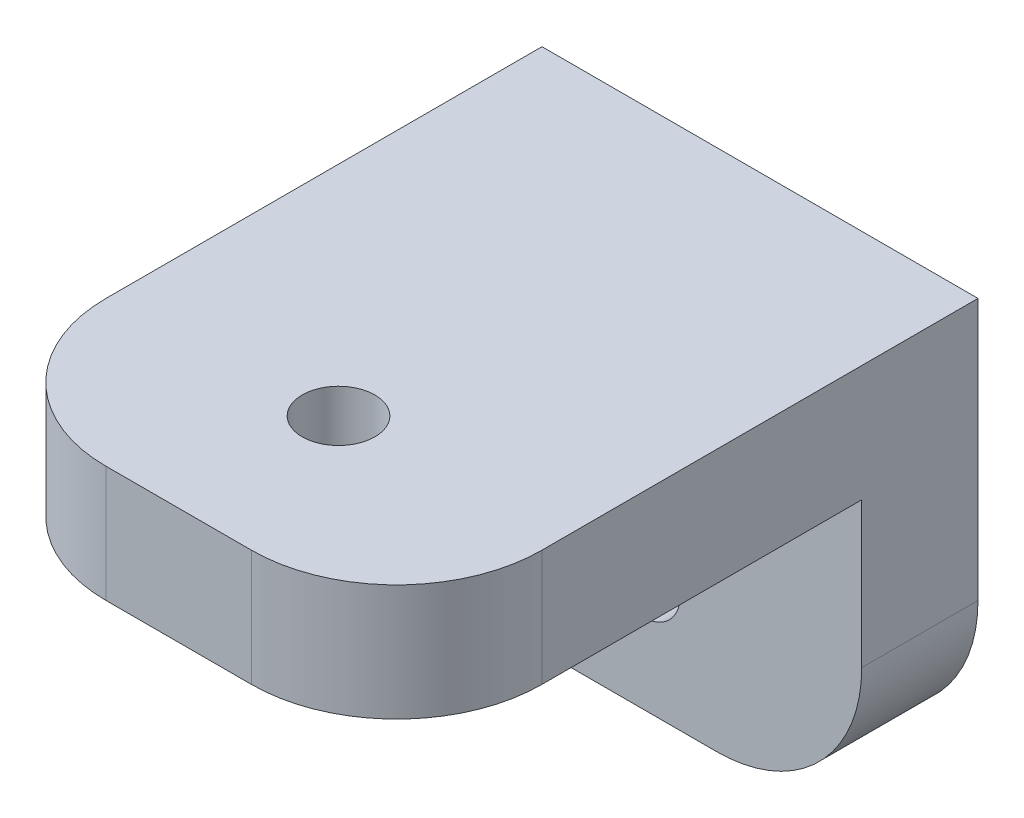
from build123d import *

# Parameters (mm, degrees)
SKETCH1_W           = 30
SKETCH1_H           = 40
BOSS_EXTRUDE1_DEPTH = 8
SKETCH2_W           = 30
SKETCH2_H           = 8
BOSS_EXTRUDE2_DEPTH = 20
SKETCH3_R           = 2.5
CUT_EXTRUDE1_DEPTH  = 10
SKETCH4_R           = 2.5
CUT_EXTRUDE2_DEPTH  = 10
FILLET2_R           = 10


with BuildPart() as part:
    # Sketch1 → Boss-Extrude1 (new body)
    with BuildSketch(Plane(origin=(0, 0, 0), x_dir=(1, 0, 0), z_dir=(0, 1, 0))):
        with Locations((15, 20)):
            Rectangle(SKETCH1_W, SKETCH1_H)
    extrude(amount=BOSS_EXTRUDE1_DEPTH)

    # Sketch2 → Boss-Extrude2 (add)
    with BuildSketch(Plane.XZ):
        with Locations((15, -36)):
            Rectangle(SKETCH2_W, SKETCH2_H)
    extrude(amount=BOSS_EXTRUDE2_DEPTH)

    # Sketch3 → Cut-Extrude1 (cut)
    with BuildSketch(Plane(origin=(0, 8, 0), x_dir=(1, 0, 0), z_dir=(0, 1, 0))):
        with Locations((15, 11)):
            Circle(SKETCH3_R)
    extrude(amount=-CUT_EXTRUDE1_DEPTH, mode=Mode.SUBTRACT)

    # Sketch4 → Cut-Extrude2 (cut)
    with BuildSketch(Plane(origin=(0, 0, -40), x_dir=(-1, 0, 0), z_dir=(0, 0, -1))):
        with Locations((-15, -12)):
            Circle(SKETCH4_R)
    extrude(amount=-CUT_EXTRUDE2_DEPTH, mode=Mode.SUBTRACT)

    # Fillet2
    fillet2_edges = [part.edges().sort_by_distance(p)[0] for p in [
        (0, -20, -36),
        (30, -20, -36),
        (30, 4, 0),
        (0, 4, 0),
    ]]
    fillet(fillet2_edges, radius=FILLET2_R)


solid = part.part
